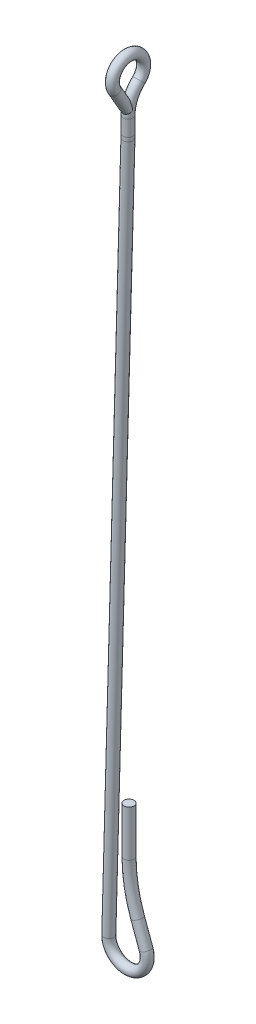
from build123d import *

# Parameters (mm, degrees)
SKETCH2_R = 1.778
SKETCH4_R = 1.778


with BuildPart() as part:
    # Sweep1: sweep along a path in Sketch1
    with BuildLine(Plane.XY) as sweep1_path:
        Line((0, 285.75), (0, 280.094610855))
        ThreePointArc((0, 280.094610855), (-0.004748195, 279.400064924), (-0.018991892, 278.70564883))
        Line((-0.018991892, 278.70564883), (-6.855436095, 28.762509873))
        ThreePointArc((-6.855436095, 28.762509873), (1.098428674, 21.805537802), (6.444411993, 30.920574143))
        Line((6.444411993, 30.920574143), (3.428113065, 39.207787339))
        ThreePointArc((3.428113065, 39.207787339), (1.136264348, 47.761083195), (0.364498201, 56.58241062))
        Line((0.364498201, 56.58241062), (0.364498201, 73.025))
    # Sketch2 → Sweep1 (sweep)
    with BuildSketch(Plane(origin=(0, 285.75, 0), x_dir=(1, 0, 0), z_dir=(0, 1, 0))):
        Circle(SKETCH2_R)
    sweep(path=sweep1_path.line)

    # Sweep2: sweep along a path in Sketch3
    with BuildLine(Plane(origin=(0, 0, 0), x_dir=(0, 0, -1), z_dir=(1, 0, 0))) as sweep2_path:
        Line((-0.254, 287.967940905), (-4.839349956, 295.91))
        ThreePointArc((-4.839349956, 295.91), (0.809947546, 304.232989869), (3.834617828, 294.639341329))
        ThreePointArc((3.834617828, 294.639341329), (0.999529614, 290.59057546), (0, 285.75))
    # Sketch4 → Sweep2 (sweep)
    with BuildSketch(Plane(origin=(0, 285.75, 0), x_dir=(1, 0, 0), z_dir=(0, 1, 0))):
        Circle(SKETCH4_R)
    sweep(path=sweep2_path.line)


solid = part.part
